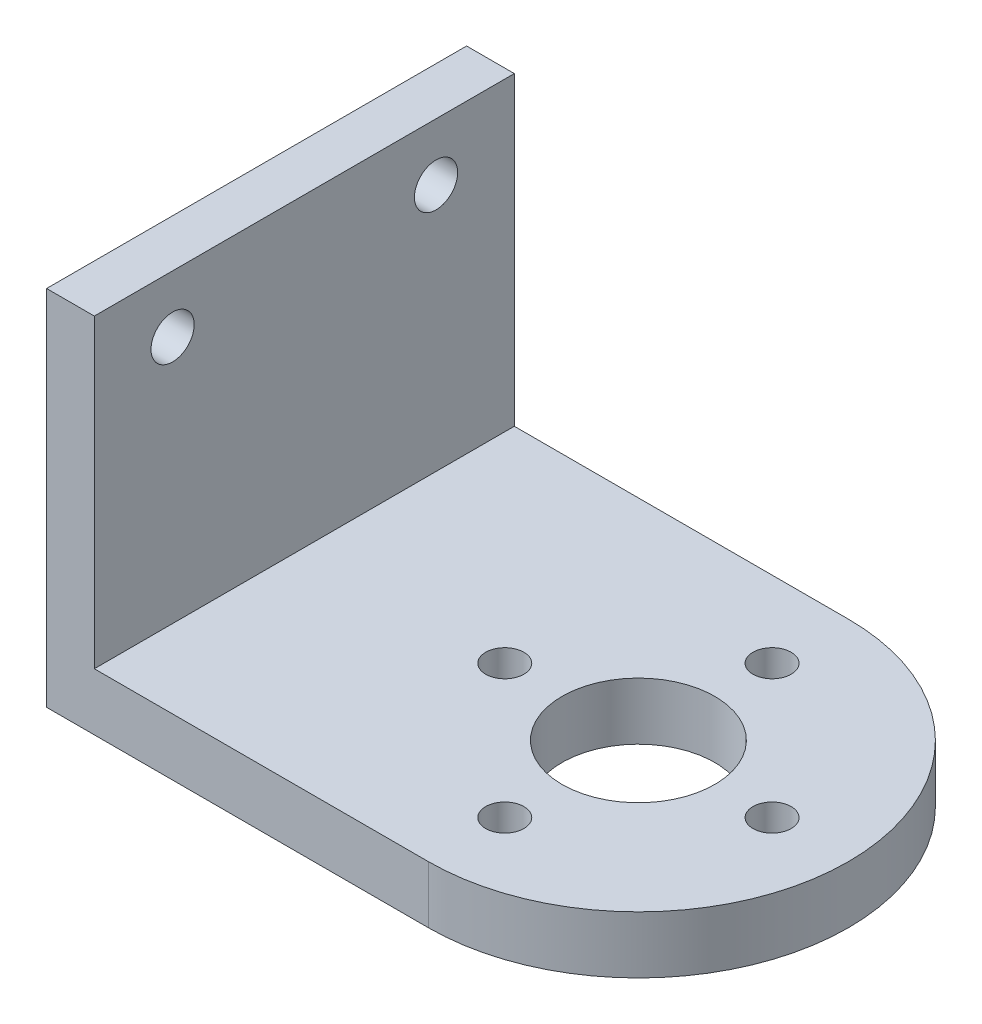
from build123d import *

# Parameters (mm, degrees)
SKETCH1_R           = 1
SKETCH1_R_2         = 4
BOSS_EXTRUDE1_DEPTH = 3
SKETCH2_W           = 2.5
SKETCH2_H           = 22
BOSS_EXTRUDE2_DEPTH = 16
SKETCH3_R           = 1.132393425
SKETCH3_R_2         = 1.130977438
CUT_EXTRUDE1_DEPTH  = 6


with BuildPart() as part:
    # Sketch1 → Boss-Extrude1 (new body)
    with BuildSketch(Plane(origin=(0, 0, 0), x_dir=(1, 0, 0), z_dir=(0, 1, 0))):
        with BuildLine():
            Line((-14, -11), (-14, 11))
            Line((-14, 11), (6, 11))
            ThreePointArc((6, 11), (17, 0), (6, -11))
            Line((6, -11), (-14, -11))
        make_face()
        with Locations((6, -7)):
            Circle(SKETCH1_R, mode=Mode.SUBTRACT)
        with Locations((-1, 0)):
            Circle(SKETCH1_R, mode=Mode.SUBTRACT)
        with Locations((6, 0)):
            Circle(SKETCH1_R_2, mode=Mode.SUBTRACT)
        with Locations((13, 0)):
            Circle(SKETCH1_R, mode=Mode.SUBTRACT)
        with Locations((6, 7)):
            Circle(SKETCH1_R, mode=Mode.SUBTRACT)
    extrude(amount=BOSS_EXTRUDE1_DEPTH)

    # Sketch2 → Boss-Extrude2 (add)
    with BuildSketch(Plane(origin=(0, 3, 0), x_dir=(1, 0, 0), z_dir=(0, 1, 0))):
        with Locations((-12.75, 0)):
            Rectangle(SKETCH2_W, SKETCH2_H)
    extrude(amount=BOSS_EXTRUDE2_DEPTH)

    # Sketch3 → Cut-Extrude1 (cut)
    with BuildSketch(Plane(origin=(-11.5, 0, 0), x_dir=(0, 0, -1), z_dir=(1, 0, 0))):
        with Locations((6.9, 16)):
            Circle(SKETCH3_R)
        with Locations((-6.9, 16)):
            Circle(SKETCH3_R_2)
    extrude(amount=-CUT_EXTRUDE1_DEPTH, mode=Mode.SUBTRACT)


solid = part.part
